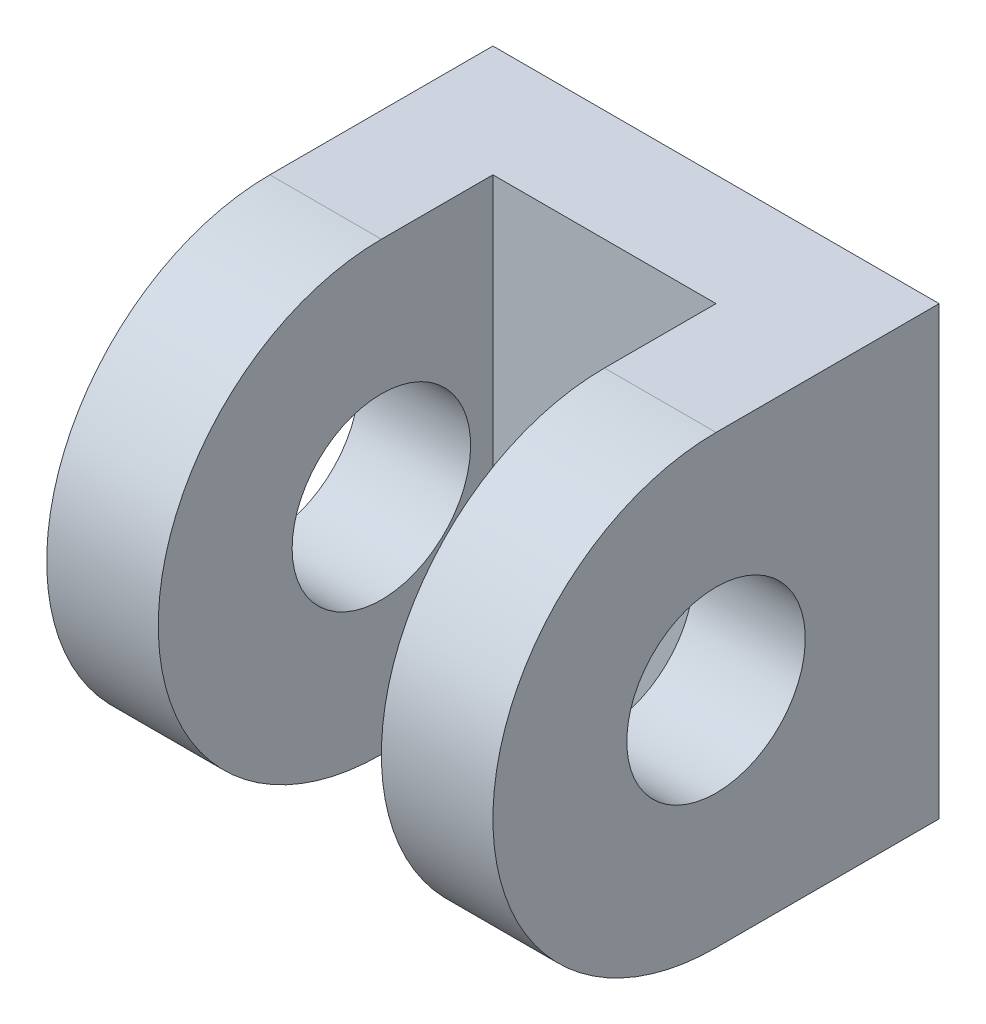
from build123d import *

# Parameters (mm, degrees)
SKETCH1_W           = 20
SKETCH1_H           = 20
BOSS_EXTRUDE1_DEPTH = 5
SKETCH2_W           = 5
SKETCH2_H           = 20
BOSS_EXTRUDE2_DEPTH = 5
SKETCH3_R           = 10
BOSS_EXTRUDE5_DEPTH = 5
SKETCH6_R           = 10
BOSS_EXTRUDE6_DEPTH = 5
SKETCH5_R           = 4
CUT_EXTRUDE1_DEPTH  = 21


with BuildPart() as part:
    # Sketch1 → Boss-Extrude1 (new body)
    with BuildSketch(Plane.XY):
        with Locations((10, 10)):
            Rectangle(SKETCH1_W, SKETCH1_H)
    extrude(amount=BOSS_EXTRUDE1_DEPTH)

    # Sketch2 → Boss-Extrude2 (add)
    with BuildSketch(Plane.XY.offset(5)):
        with Locations((2.5, 10)):
            Rectangle(SKETCH2_W, SKETCH2_H)
        with Locations((17.5, 10)):
            Rectangle(SKETCH2_W, SKETCH2_H)
    extrude(amount=BOSS_EXTRUDE2_DEPTH)

    # Sketch3 → Boss-Extrude5 (add)
    with BuildSketch(Plane(origin=(20, 0, 0), x_dir=(0, 0, -1), z_dir=(1, 0, 0))):
        with Locations((-10, 10)):
            Circle(SKETCH3_R)
    extrude(amount=-BOSS_EXTRUDE5_DEPTH)

    # Sketch6 → Boss-Extrude6 (add)
    with BuildSketch(Plane.ZY):
        with Locations((10, 10)):
            Circle(SKETCH6_R)
    extrude(amount=-BOSS_EXTRUDE6_DEPTH)

    # Sketch5 → Cut-Extrude1 (cut, through all)
    with BuildSketch(Plane(origin=(20, 0, 0), x_dir=(0, 0, -1), z_dir=(1, 0, 0))):
        with Locations((-10, 10)):
            Circle(SKETCH5_R)
    extrude(amount=-CUT_EXTRUDE1_DEPTH, mode=Mode.SUBTRACT)


solid = part.part
